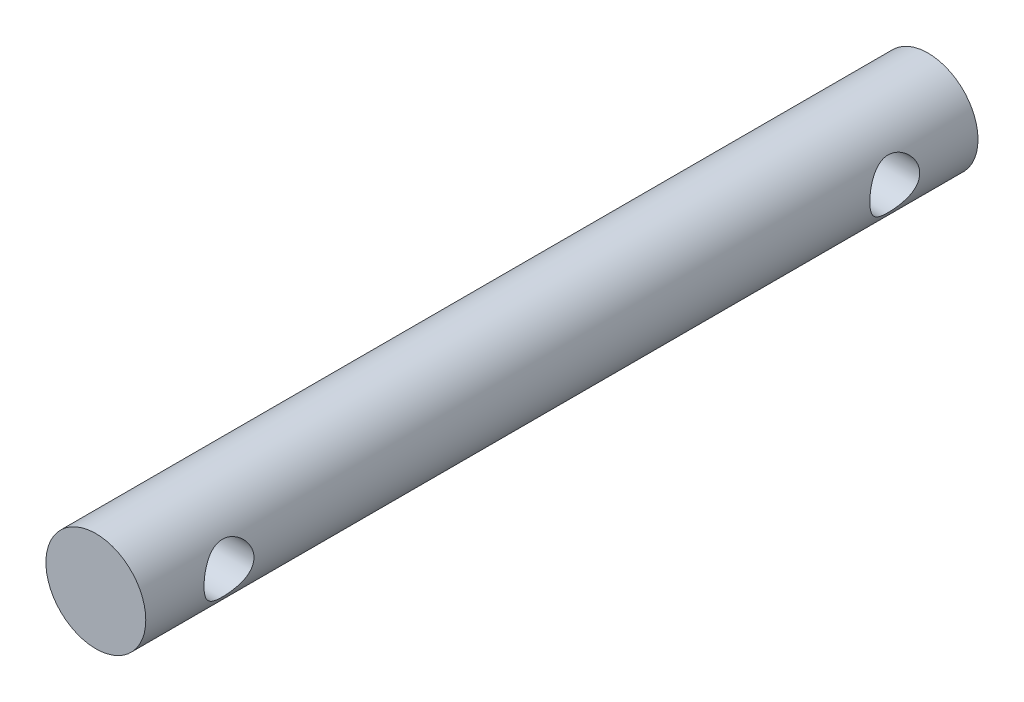
from build123d import *

# Parameters (mm, degrees)
SKETCH1_R               = 3
BOSS_EXTRUDE1_DEPTH     = 50
SKETCH2_R               = 1.5
CUT_EXTRUDE1_DEPTH      = 4
CUT_EXTRUDE1_DEPTH_BACK = 4


with BuildPart() as part:
    # Sketch1 → Boss-Extrude1 (new body)
    with BuildSketch(Plane.XY):
        Circle(SKETCH1_R)
    extrude(amount=BOSS_EXTRUDE1_DEPTH)

    # Sketch2 → Cut-Extrude1 (cut, two sides)
    with BuildSketch(Plane(origin=(0, 0, 0), x_dir=(0, 0, -1), z_dir=(1, 0, 0))) as cut_extrude1_sk:
        with Locations((-45, 0)):
            Circle(SKETCH2_R)
        with Locations((-5, 0)):
            Circle(SKETCH2_R)
    extrude(amount=CUT_EXTRUDE1_DEPTH, mode=Mode.SUBTRACT)
    extrude(cut_extrude1_sk.sketch, amount=-CUT_EXTRUDE1_DEPTH_BACK, mode=Mode.SUBTRACT)


solid = part.part
